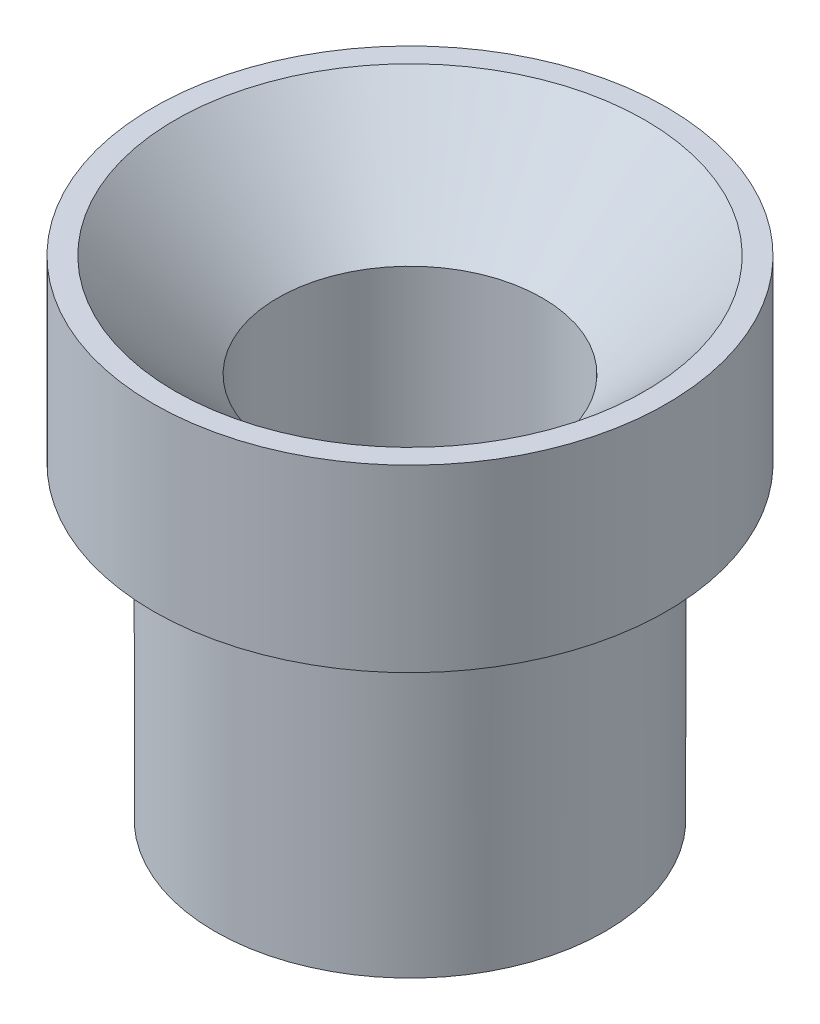
from build123d import *

# Parameters (mm, degrees)
SKETCH1_R           = 5
BOSS_EXTRUDE1_DEPTH = 3.5
SKETCH2_R           = 2.575
CUT_EXTRUDE1_DEPTH  = 3.5
CHAMFER1_SIZE       = 2
SKETCH3_R           = 3.8
BOSS_EXTRUDE2_DEPTH = 6
SKETCH4_R           = 2.575
CUT_EXTRUDE2_DEPTH  = 6


with BuildPart() as part:
    # Sketch1 → Boss-Extrude1 (new body)
    with BuildSketch(Plane(origin=(0, 0, 0), x_dir=(1, 0, 0), z_dir=(0, 1, 0))):
        Circle(SKETCH1_R)
    extrude(amount=BOSS_EXTRUDE1_DEPTH)

    # Sketch2 → Cut-Extrude1 (cut)
    with BuildSketch(Plane(origin=(0, 3.5, 0), x_dir=(1, 0, 0), z_dir=(0, 1, 0))):
        Circle(SKETCH2_R)
    extrude(amount=-CUT_EXTRUDE1_DEPTH, mode=Mode.SUBTRACT)

    # Chamfer1
    chamfer1_edges = [part.edges().sort_by_distance(p)[0] for p in [
        (-2.575, 3.5, 0),
    ]]
    chamfer(chamfer1_edges, length=CHAMFER1_SIZE)

    # Sketch3 → Boss-Extrude2 (add)
    with BuildSketch(Plane.XZ):
        Circle(SKETCH3_R)
    extrude(amount=BOSS_EXTRUDE2_DEPTH)

    # Sketch4 → Cut-Extrude2 (cut)
    with BuildSketch(Plane.XZ.offset(6)):
        Circle(SKETCH4_R)
    extrude(amount=-CUT_EXTRUDE2_DEPTH, mode=Mode.SUBTRACT)


solid = part.part
